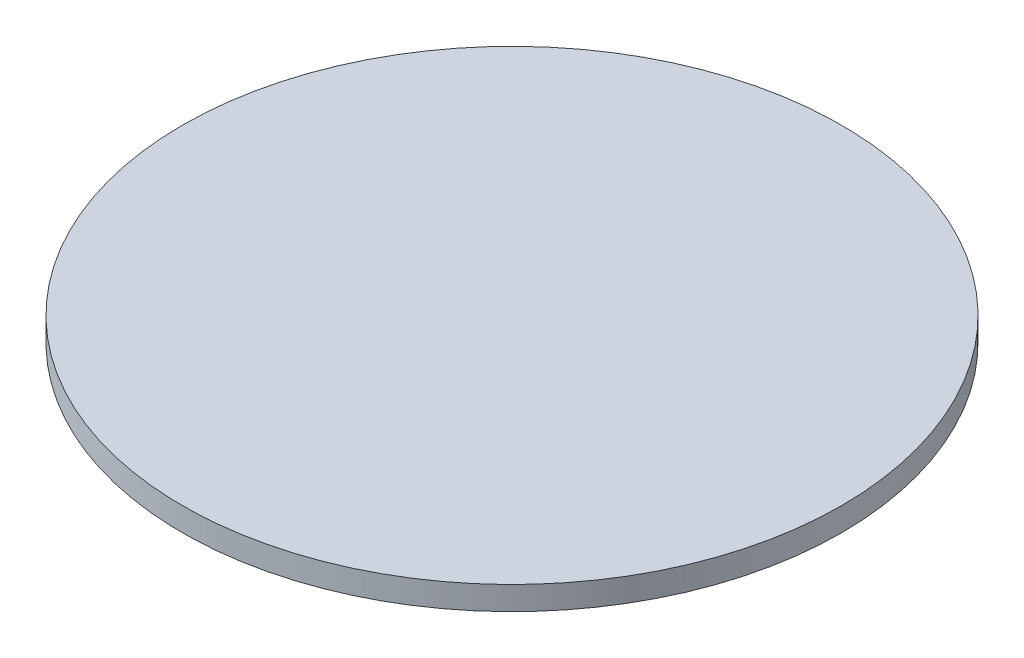
from build123d import *


with BuildPart() as part:
    # Sketch1 → Revolve1 (revolve)
    with BuildSketch(Plane.XY):
        Polygon((0, 1), (14, 1), (14, 0), (13.5, 0), (13.5, 0.7), (0, 0.7), align=None)
    revolve(axis=Axis((0, 0, 0), (0, 1, 0)))


solid = part.part
